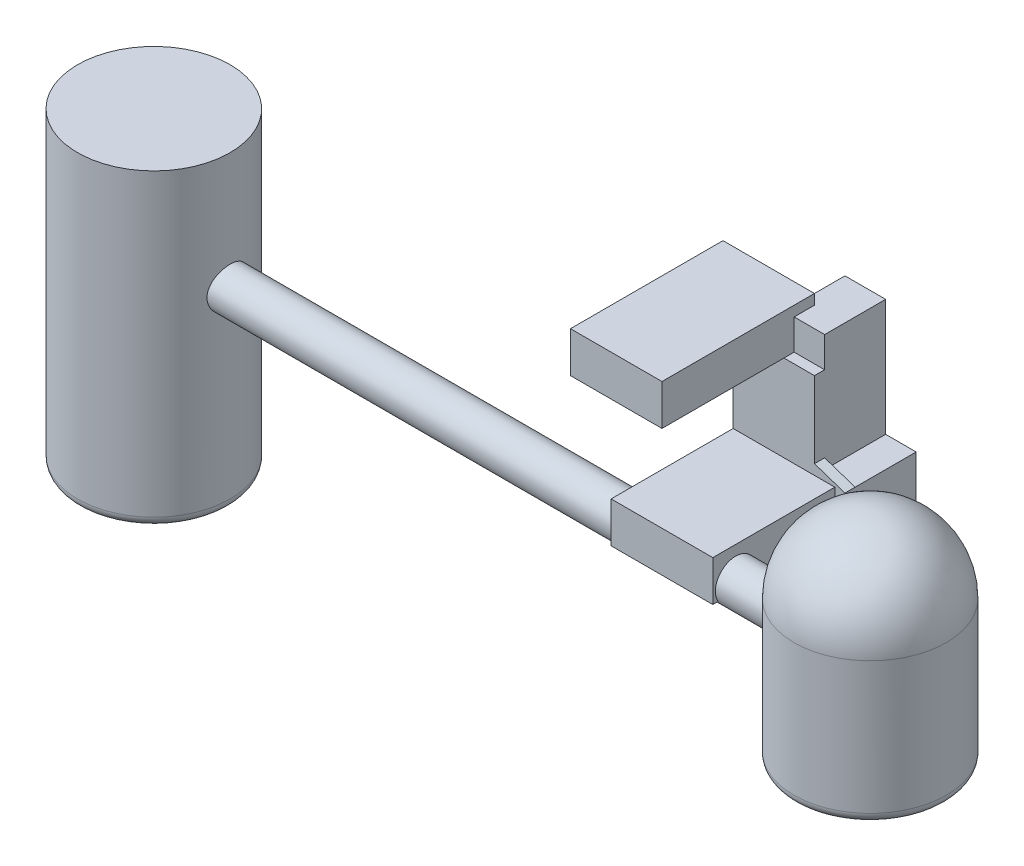
from build123d import *

# Parameters (mm, degrees)
SKETCH1_W                 = 9000
SKETCH1_H                 = 15000
BOSS_EXTRUDE1_DEPTH       = 4000
SKETCH2_W                 = 3000
SKETCH2_H                 = 3000
SKETCH2_W_2               = 1000
BOSS_EXTRUDE2_DEPTH       = 4000
BOSS_EXTRUDE2_DEPTH_BACK  = 2000
SKETCH3_W                 = 11000
SKETCH3_H                 = 7000
BOSS_EXTRUDE3_DEPTH       = 12500
SKETCH4_W                 = 7000
SKETCH4_H                 = 4000
BOSS_EXTRUDE4_DEPTH       = 1500
SKETCH5_W                 = 10000
SKETCH5_H                 = 4000
BOSS_EXTRUDE5_DEPTH       = 12000
SKETCH6_R                 = 2000
BOSS_EXTRUDE6_DEPTH       = 6000
SKETCH9_R                 = 7500
BOSS_EXTRUDE8_DEPTH       = 10000
BOSS_EXTRUDE8_DEPTH_BACK  = 4000
REVOLVE5_ANGLE            = 180
BOSS_EXTRUDE9_DEPTH       = 40000
SKETCH16_R                = 7500
BOSS_EXTRUDE11_DEPTH      = 20000
BOSS_EXTRUDE11_DEPTH_BACK = 10500
BOSS_EXTRUDE12_DEPTH      = 10000
FILLET1_R                 = 1000
FILLET2_R                 = 1000
SKETCH19_W                = 3000
SKETCH19_H                = 6000
CUT_EXTRUDE1_DEPTH        = 8500
CUT_EXTRUDE2_DEPTH        = 6001
CUT_EXTRUDE2_DEPTH_BACK   = 18251.0000001


with BuildPart() as part:
    # Sketch1 → Boss-Extrude1 (new body)
    with BuildSketch(Plane(origin=(0, 0, 0), x_dir=(1, 0, 0), z_dir=(0, 1, 0))):
        Rectangle(SKETCH1_W, SKETCH1_H)
    extrude(amount=BOSS_EXTRUDE1_DEPTH)

    # Sketch2 → Boss-Extrude2 (add, two sides)
    with BuildSketch(Plane(origin=(0, 0, -7500), x_dir=(-1, 0, 0), z_dir=(0, 0, -1))) as boss_extrude2_sk:
        with Locations((-6000, 1500)):
            Rectangle(SKETCH2_W, SKETCH2_H)
        with Locations((-4000, 1500)):
            Rectangle(SKETCH2_W_2, SKETCH2_H)
    extrude(amount=BOSS_EXTRUDE2_DEPTH)
    extrude(boss_extrude2_sk.sketch, amount=-BOSS_EXTRUDE2_DEPTH_BACK)

    # Sketch3 → Boss-Extrude3 (add)
    with BuildSketch(Plane.XZ):
        with Locations((5000, -8000)):
            Rectangle(SKETCH3_W, SKETCH3_H)
    extrude(amount=BOSS_EXTRUDE3_DEPTH)

    # Sketch4 → Boss-Extrude4 (add)
    with BuildSketch(Plane.XZ.offset(12500)):
        with Locations((7000, -9500)):
            Rectangle(SKETCH4_W, SKETCH4_H)
    extrude(amount=BOSS_EXTRUDE4_DEPTH)

    # Sketch5 → Boss-Extrude5 (add)
    with BuildSketch(Plane.XY.offset(-4500)):
        with Locations((4500, -10500)):
            Rectangle(SKETCH5_W, SKETCH5_H)
    extrude(amount=BOSS_EXTRUDE5_DEPTH)

    # Sketch6 → Boss-Extrude6 (add)
    with BuildSketch(Plane(origin=(9500, 0, 0), x_dir=(0, 0, -1), z_dir=(1, 0, 0))):
        with Locations((-5250, -11500)):
            Circle(SKETCH6_R)
    extrude(amount=BOSS_EXTRUDE6_DEPTH)

    # Sketch9 → Boss-Extrude8 (add, two sides)
    with BuildSketch(Plane(origin=(0, -10500, 0), x_dir=(-1, 0, 0), z_dir=(0, -1, 0))) as boss_extrude8_sk:
        with Locations((-22728.4161474, -5250)):
            Circle(SKETCH9_R)
    extrude(amount=BOSS_EXTRUDE8_DEPTH)
    extrude(boss_extrude8_sk.sketch, amount=-BOSS_EXTRUDE8_DEPTH_BACK)

    # Sketch10 → Revolve5 (revolve)
    with BuildSketch(Plane(origin=(0, -6500, 0), x_dir=(1, 0, 0), z_dir=(0, 1, 0))):
        with BuildLine():
            Line((15228.4161474, -5250), (30228.4161474, -5250))
            ThreePointArc((30228.4161474, -5250), (22728.4161474, 2250), (15228.4161474, -5250))
        make_face()
    revolve(axis=Axis((15228.4161474, -6500, 5250), (1, 0, 0)), revolution_arc=REVOLVE5_ANGLE)

    # Sketch12 → Boss-Extrude9 (add)
    with BuildSketch(Plane.ZY.offset(500)):
        with BuildLine():
            ThreePointArc((3517.949192431, -12500), (5250, -13500), (6982.050807569, -12500))
            ThreePointArc((6982.050807569, -12500), (5250, -9500), (3517.949192431, -12500))
        make_face()
    extrude(amount=BOSS_EXTRUDE9_DEPTH)

    # Sketch16 → Boss-Extrude11 (add, two sides)
    with BuildSketch(Plane(origin=(0, -10500, 0), x_dir=(-1, 0, 0), z_dir=(0, -1, 0))) as boss_extrude11_sk:
        with Locations((47728.4161474, -5250)):
            Circle(SKETCH16_R)
    extrude(amount=BOSS_EXTRUDE11_DEPTH)
    extrude(boss_extrude11_sk.sketch, amount=-BOSS_EXTRUDE11_DEPTH_BACK)

    # Sketch18 → Boss-Extrude12 (add)
    with BuildSketch(Plane(origin=(-500, 0, 0), x_dir=(0, 0, -1), z_dir=(1, 0, 0))):
        with BuildLine():
            Line((-3517.949192431, -12500), (-6982.050807569, -12500))
            ThreePointArc((-6982.050807569, -12500), (-5250, -13500), (-3517.949192431, -12500))
        make_face()
    extrude(amount=BOSS_EXTRUDE12_DEPTH)

    # Fillet1
    fillet1_edges = [part.edges().sort_by_distance(p)[0] for p in [
        (30228.4161474, -20500, 5250),
    ]]
    fillet(fillet1_edges, radius=FILLET1_R)

    # Fillet2
    fillet2_edges = [part.edges().sort_by_distance(p)[0] for p in [
        (-40228.4161474, -30500, 5250),
    ]]
    fillet(fillet2_edges, radius=FILLET2_R)

    # Sketch19 → Cut-Extrude1 (cut)
    with BuildSketch(Plane(origin=(0, 0, 0), x_dir=(1, 0, 0), z_dir=(0, 1, 0))):
        with Locations((9000, 8500)):
            Rectangle(SKETCH19_W, SKETCH19_H)
    extrude(amount=-CUT_EXTRUDE1_DEPTH, mode=Mode.SUBTRACT)

    # Sketch20 → Cut-Extrude2 (cut, two sides)
    with BuildSketch(Plane(origin=(0, 0, -5500), x_dir=(-1, 0, 0), z_dir=(0, 0, -1))) as cut_extrude2_sk:
        Polygon((-10500, 0), (-10500, -8500), (-7500, -7500), (-7500, 0), align=None)
    extrude(amount=CUT_EXTRUDE2_DEPTH, mode=Mode.SUBTRACT)
    extrude(cut_extrude2_sk.sketch, amount=-CUT_EXTRUDE2_DEPTH_BACK, mode=Mode.SUBTRACT)


solid = part.part
